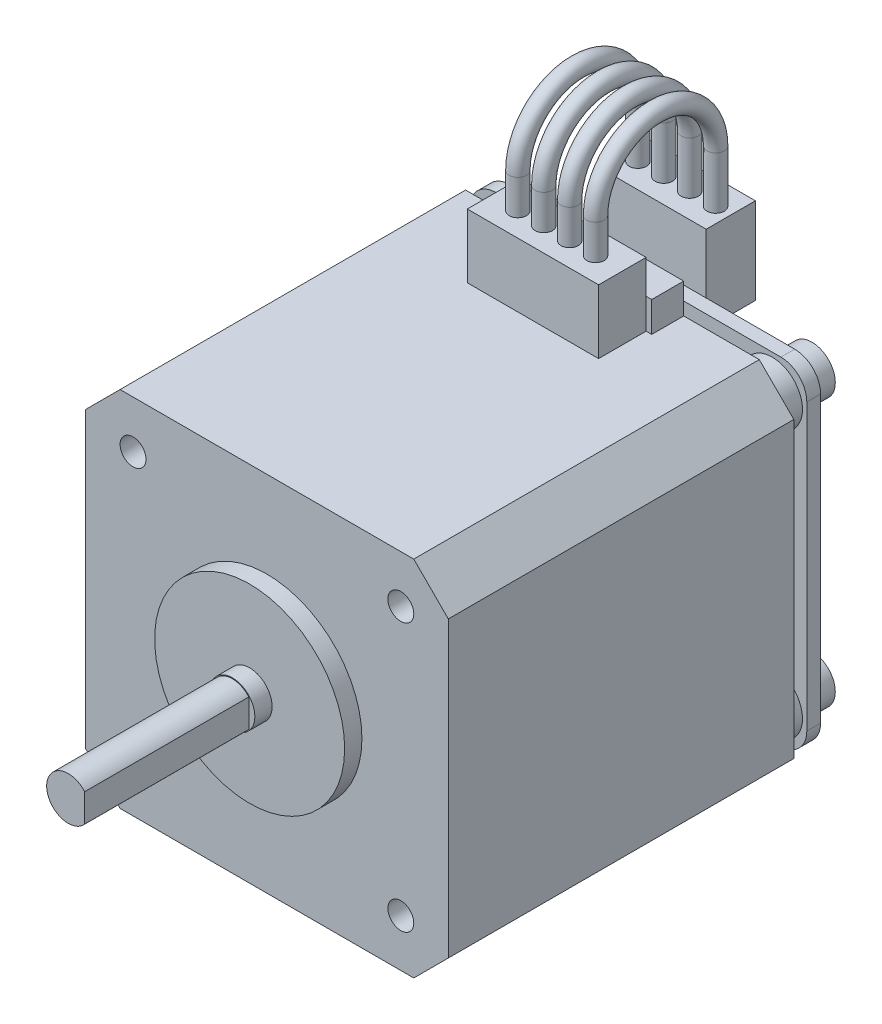
from build123d import *

# Parameters (mm, degrees)
SKETCH1_R            = 11
BOSS_EXTRUDE1_DEPTH  = 2
SKETCH2_R            = 2.6
BOSS_EXTRUDE2_DEPTH  = 21
CUT_EXTRUDE1_DEPTH   = 19
SKETCH4_W            = 42
SKETCH4_H            = 42
BOSS_EXTRUDE3_DEPTH  = 40
CHAMFER1_SIZE        = 4
CUT_EXTRUDE2_DEPTH   = 64
SKETCH6_R            = 3.5
BOSS_EXTRUDE4_DEPTH  = 3
SKETCH7_W            = 39
SKETCH7_H            = 39
BOSS_EXTRUDE5_DEPTH  = 1.6
FILLET1_R            = 3
SKETCH8_W            = 16.5
SKETCH8_H            = 7
BOSS_EXTRUDE6_DEPTH  = 3.7
SKETCH9_W            = 15.2
SKETCH9_H            = 5.5
BOSS_EXTRUDE7_DEPTH  = 7.4
SKETCH10_W           = 12.5
SKETCH10_H           = 10
BOSS_EXTRUDE8_DEPTH  = 5.7
SKETCH11_R           = 1
SKETCH13_R           = 2.7
BOSS_EXTRUDE9_DEPTH  = 3
SKETCH14_W           = 12
SKETCH14_H           = 10
BOSS_EXTRUDE10_DEPTH = 2
SKETCH15_W           = 5
SKETCH15_H           = 3
BOSS_EXTRUDE11_DEPTH = 4
SKETCH16_W           = 7.2
SKETCH16_H           = 17.5
BOSS_EXTRUDE12_DEPTH = 5.7
SKETCH17_R           = 3.199727203
SKETCH17_R_2         = 2.5
CUT_EXTRUDE3_DEPTH   = 19


with BuildPart() as part:
    # Sketch1 → Boss-Extrude1 (new body)
    with BuildSketch(Plane.XY):
        Circle(SKETCH1_R)
    extrude(amount=BOSS_EXTRUDE1_DEPTH)

    # Sketch2 → Boss-Extrude2 (add)
    with BuildSketch(Plane.XY.offset(2)):
        Circle(SKETCH2_R)
    extrude(amount=BOSS_EXTRUDE2_DEPTH)

    # Sketch3 → Cut-Extrude1 (cut)
    with BuildSketch(Plane.XY.offset(23)):
        with BuildLine():
            Line((1.9, 1.774823935), (1.9, -1.774823935))
            ThreePointArc((1.9, -1.774823935), (2.6, 0), (1.9, 1.774823935))
        make_face()
    extrude(amount=-CUT_EXTRUDE1_DEPTH, mode=Mode.SUBTRACT)

    # Sketch4 → Boss-Extrude3 (add)
    with BuildSketch(Plane(origin=(0, 0, 0), x_dir=(-1, 0, 0), z_dir=(0, 0, -1))):
        Rectangle(SKETCH4_W, SKETCH4_H)
    extrude(amount=BOSS_EXTRUDE3_DEPTH)

    # Chamfer1
    chamfer1_edges = [part.edges().sort_by_distance(p)[0] for p in [
        (-21, -21, -20),
        (-21, 21, -20),
        (21, 21, -20),
        (21, -21, -20),
    ]]
    chamfer(chamfer1_edges, length=CHAMFER1_SIZE)

    # Sketch5 → Cut-Extrude2 (cut, through all)
    with BuildSketch(Plane(origin=(0, 0, -40), x_dir=(-1, 0, 0), z_dir=(0, 0, -1))):
        with BuildLine():
            ThreePointArc((-14, 15.5), (-16.560660172, 16.560660172), (-15.5, 14))
            Line((-15.5, 14), (-15.5, 15.5))
            Line((-15.5, 15.5), (-14, 15.5))
        make_face()
        with BuildLine():
            Line((-15.5, 15.5), (-15.5, 14))
            ThreePointArc((-15.5, 14), (-14.439339828, 14.439339828), (-14, 15.5))
            Line((-14, 15.5), (-15.5, 15.5))
        make_face()
        with BuildLine():
            ThreePointArc((14, 15.5), (14.439339828, 14.439339828), (15.5, 14))
            Line((15.5, 14), (15.5, 15.5))
            Line((15.5, 15.5), (14, 15.5))
        make_face()
        with BuildLine():
            Line((15.5, 15.5), (15.5, 14))
            ThreePointArc((15.5, 14), (16.560660172, 14.439339828), (17, 15.5))
            ThreePointArc((17, 15.5), (15.5, 17), (14, 15.5))
            Line((14, 15.5), (15.5, 15.5))
        make_face()
        with BuildLine():
            ThreePointArc((15.5, -14), (14.439339828, -14.439339828), (14, -15.5))
            Line((14, -15.5), (15.5, -15.5))
            Line((15.5, -15.5), (15.5, -14))
        make_face()
        with BuildLine():
            Line((15.5, -15.5), (14, -15.5))
            ThreePointArc((14, -15.5), (15.5, -17), (17, -15.5))
            ThreePointArc((17, -15.5), (16.560660172, -14.439339828), (15.5, -14))
            Line((15.5, -14), (15.5, -15.5))
        make_face()
        with BuildLine():
            Line((-15.5, -14), (-15.5, -15.5))
            Line((-15.5, -15.5), (-14, -15.5))
            ThreePointArc((-14, -15.5), (-14.439339828, -14.439339828), (-15.5, -14))
        make_face()
        with BuildLine():
            Line((-14, -15.5), (-15.5, -15.5))
            Line((-15.5, -15.5), (-15.5, -14))
            ThreePointArc((-15.5, -14), (-16.560660172, -16.560660172), (-14, -15.5))
        make_face()
    extrude(amount=-CUT_EXTRUDE2_DEPTH, mode=Mode.SUBTRACT)

    # Sketch6 → Boss-Extrude4 (add)
    with BuildSketch(Plane(origin=(0, 0, -40), x_dir=(-1, 0, 0), z_dir=(0, 0, -1))):
        with Locations((-15.5, 15.5)):
            Circle(SKETCH6_R)
        with Locations((15.5, 15.5)):
            Circle(SKETCH6_R)
        with Locations((15.5, -15.5)):
            Circle(SKETCH6_R)
        with Locations((-15.5, -15.5)):
            Circle(SKETCH6_R)
    extrude(amount=BOSS_EXTRUDE4_DEPTH)

    # Sketch7 → Boss-Extrude5 (add)
    with BuildSketch(Plane(origin=(0, 0, -43), x_dir=(-1, 0, 0), z_dir=(0, 0, -1))):
        Rectangle(SKETCH7_W, SKETCH7_H)
    extrude(amount=BOSS_EXTRUDE5_DEPTH)

    # Fillet1
    fillet1_edges = [part.edges().sort_by_distance(p)[0] for p in [
        (19.5, 19.5, -43.8),
        (19.5, -19.5, -43.8),
        (-19.5, -19.5, -43.8),
        (-19.5, 19.5, -43.8),
    ]]
    fillet(fillet1_edges, radius=FILLET1_R)

    # Sketch8 → Boss-Extrude6 (add)
    with BuildSketch(Plane(origin=(0, 0, -40), x_dir=(-1, 0, 0), z_dir=(0, 0, -1))):
        with Locations((0, 21)):
            Rectangle(SKETCH8_W, SKETCH8_H)
    extrude(amount=-BOSS_EXTRUDE6_DEPTH)

    # Sketch9 → Boss-Extrude7 (add)
    with BuildSketch(Plane(origin=(0, 21, 0), x_dir=(1, 0, 0), z_dir=(0, 1, 0))):
        with Locations((0, 33.55)):
            Rectangle(SKETCH9_W, SKETCH9_H)
    extrude(amount=BOSS_EXTRUDE7_DEPTH)

    # Sketch10 → Boss-Extrude8 (add)
    with BuildSketch(Plane(origin=(0, 0, -44.6), x_dir=(-1, 0, 0), z_dir=(0, 0, -1))):
        with Locations((0, 21.4)):
            Rectangle(SKETCH10_W, SKETCH10_H)
    extrude(amount=BOSS_EXTRUDE8_DEPTH)

    # Sweep1: sweep along a path in Sketch12
    with BuildLine(Plane(origin=(0, 0, 0), x_dir=(0, 0, -1), z_dir=(1, 0, 0))) as sweep1_path:
        Line((33.55, 28.4), (33.55, 32.45))
        ThreePointArc((33.55, 32.45), (40.5, 39.4), (47.45, 32.45))
        Line((47.45, 32.45), (47.45, 26.4))
    # Sketch11 → Sweep1 (sweep)
    with BuildSketch(Plane(origin=(0, 26.4, 0), x_dir=(1, 0, 0), z_dir=(0, 1, 0))):
        with Locations((-4.5, 47.45)):
            Circle(SKETCH11_R)
        with Locations((-1.5, 47.45)):
            Circle(SKETCH11_R)
        with Locations((1.5, 47.45)):
            Circle(SKETCH11_R)
        with Locations((4.5, 47.45)):
            Circle(SKETCH11_R)
    sweep(path=sweep1_path.line)

    # Sketch13 → Boss-Extrude9 (add)
    with BuildSketch(Plane(origin=(0, 0, -44.6), x_dir=(-1, 0, 0), z_dir=(0, 0, -1))):
        with Locations((-15.5, 15.5)):
            Circle(SKETCH13_R)
        with Locations((15.5, 15.5)):
            Circle(SKETCH13_R)
        with Locations((-15.5, -15.5)):
            Circle(SKETCH13_R)
        with Locations((15.5, -15.5)):
            Circle(SKETCH13_R)
    extrude(amount=BOSS_EXTRUDE9_DEPTH)

    # Sketch14 → Boss-Extrude10 (add)
    with BuildSketch(Plane(origin=(0, 0, -44.6), x_dir=(-1, 0, 0), z_dir=(0, 0, -1))):
        Rectangle(SKETCH14_W, SKETCH14_H)
    extrude(amount=BOSS_EXTRUDE10_DEPTH)

    # Sketch15 → Boss-Extrude11 (add)
    with BuildSketch(Plane(origin=(0, 0, -44.6), x_dir=(-1, 0, 0), z_dir=(0, 0, -1))):
        with Locations((-8, -17.5)):
            Rectangle(SKETCH15_W, SKETCH15_H)
        with Locations((0, -17.5)):
            Rectangle(SKETCH15_W, SKETCH15_H)
        with Locations((8, -17.5)):
            Rectangle(SKETCH15_W, SKETCH15_H)
    extrude(amount=BOSS_EXTRUDE11_DEPTH)

    # Sketch16 → Boss-Extrude12 (add)
    with BuildSketch(Plane(origin=(0, 0, -44.6), x_dir=(-1, 0, 0), z_dir=(0, 0, -1))):
        with Locations((20.4, 0)):
            Rectangle(SKETCH16_W, SKETCH16_H)
    extrude(amount=BOSS_EXTRUDE12_DEPTH)

    # Sketch17 → Cut-Extrude3 (cut)
    with BuildSketch(Plane.XY.offset(23)):
        Circle(SKETCH17_R)
        Circle(SKETCH17_R_2, mode=Mode.SUBTRACT)
    extrude(amount=-CUT_EXTRUDE3_DEPTH, mode=Mode.SUBTRACT)


solid = part.part
